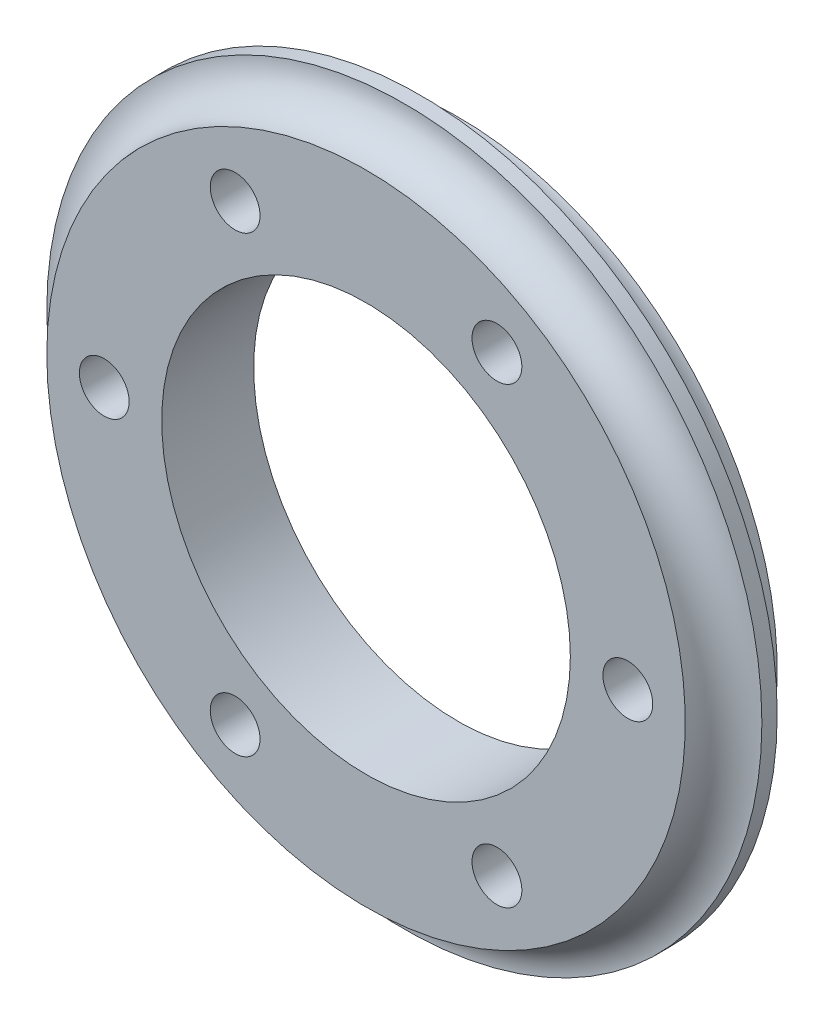
from build123d import *

# Parameters (mm, degrees)
SKETCH2_R           = 23.335
SKETCH2_R_2         = 13.335
BOSS_EXTRUDE1_DEPTH = 6
SKETCH3_R           = 2.5
SKETCH4_R           = 1.625
CUT_EXTRUDE1_DEPTH  = 7


with BuildPart() as part:
    # Sketch2 → Boss-Extrude1 (new body)
    with BuildSketch(Plane.XY):
        Circle(SKETCH2_R)
        Circle(SKETCH2_R_2, mode=Mode.SUBTRACT)
    extrude(amount=BOSS_EXTRUDE1_DEPTH)

    # Sketch3 → Cut-Revolve1 (revolve, cut)
    with BuildSketch(Plane(origin=(0, 0, 0), x_dir=(1, 0, 0), z_dir=(0, 1, 0))):
        with Locations((-23.335, 0)):
            Circle(SKETCH3_R)
        with Locations((-23.335, -6)):
            Circle(SKETCH3_R)
    revolve(axis=Axis((0, 0, 6), (0, 0, -1)), mode=Mode.SUBTRACT)

    # Sketch4 → Cut-Extrude1 (cut, through all)
    with BuildSketch(Plane(origin=(0, 0, 0), x_dir=(-1, 0, 0), z_dir=(0, 0, -1))):
        with Locations((8.5425, 14.796044024)):
            Circle(SKETCH4_R)
        with Locations((-8.5425, 14.796044024)):
            Circle(SKETCH4_R)
        with Locations((-17.085, 0)):
            Circle(SKETCH4_R)
        with Locations((-8.5425, -14.796044024)):
            Circle(SKETCH4_R)
        with Locations((8.5425, -14.796044024)):
            Circle(SKETCH4_R)
        with Locations((17.085, 0)):
            Circle(SKETCH4_R)
    extrude(amount=-CUT_EXTRUDE1_DEPTH, mode=Mode.SUBTRACT)


solid = part.part
